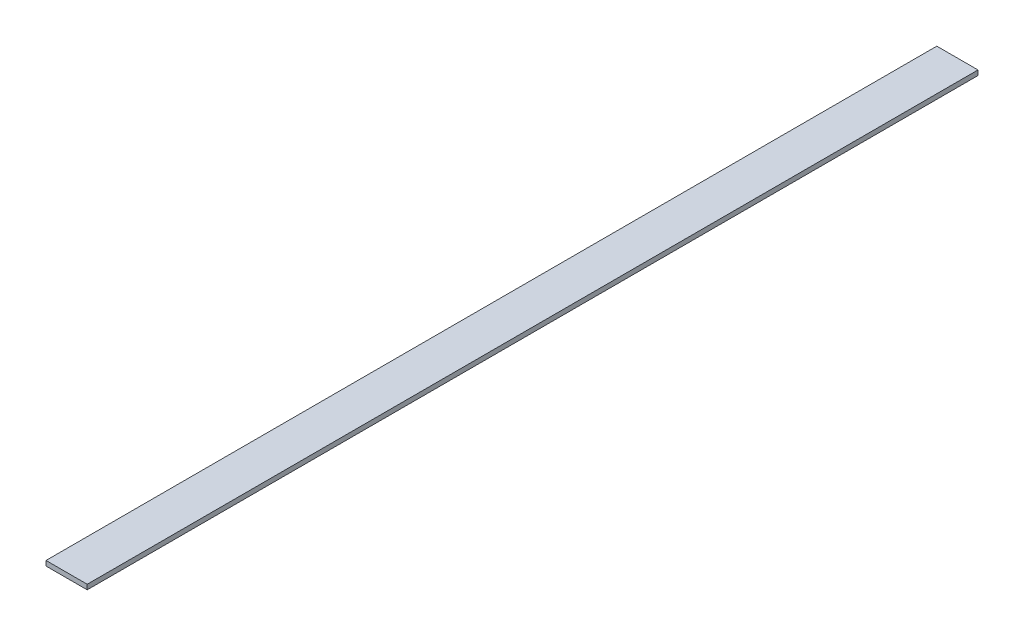
from build123d import *

# Parameters (mm, degrees)
SKETCH1_W           = 25.4
SKETCH1_H           = 549.2
BOSS_EXTRUDE1_DEPTH = 3


with BuildPart() as part:
    # Sketch1 → Boss-Extrude1 (new body)
    with BuildSketch(Plane(origin=(0, 334.925662842, 0), x_dir=(1, 0, 0), z_dir=(0, 1, 0))):
        with Locations((-12.400127241, -229.282719675)):
            Rectangle(SKETCH1_W, SKETCH1_H)
    extrude(amount=BOSS_EXTRUDE1_DEPTH)


solid = part.part
